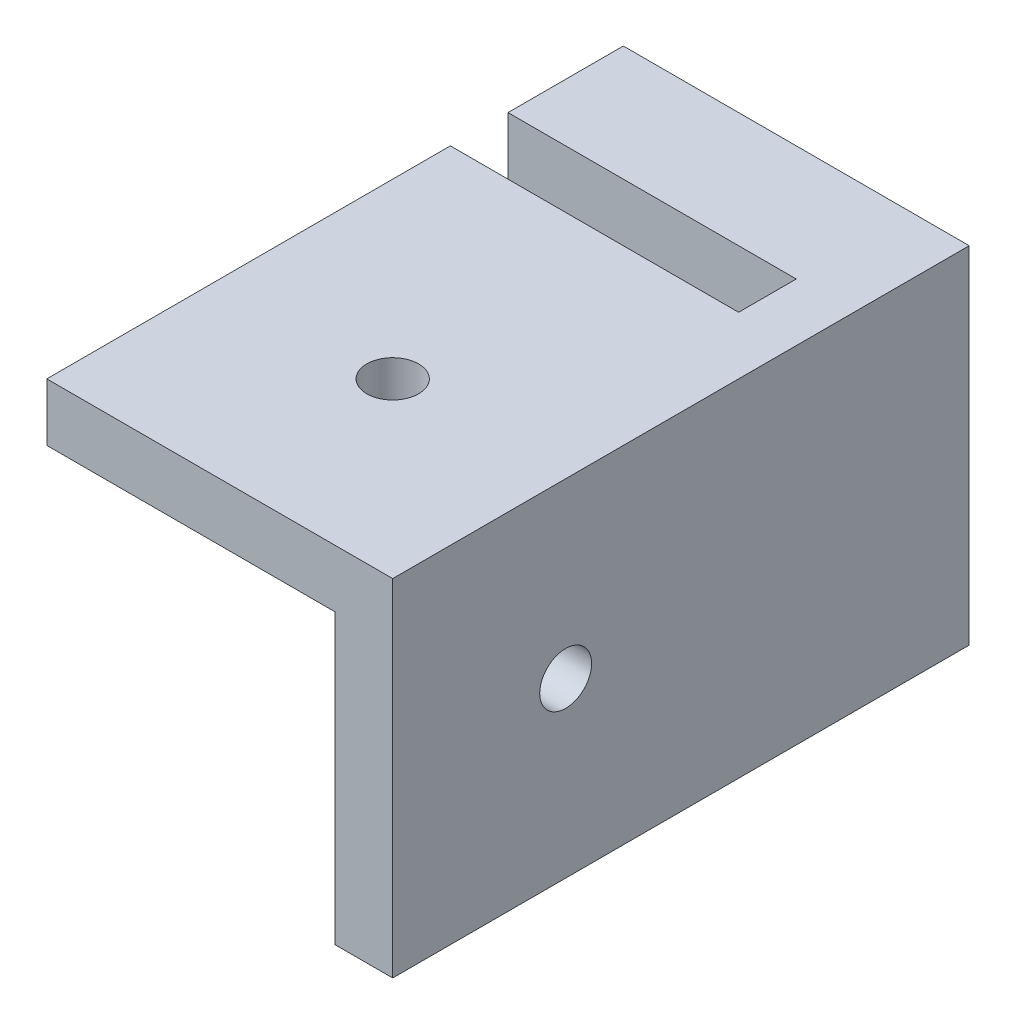
from build123d import *

# Parameters (mm, degrees)
ESBO_O1_W                         = 30
ESBO_O1_H                         = 30
RESSALTO_EXTRUS_O1_DEPTH          = 50
ESBO_O2_W                         = 25
ESBO_O2_H                         = 5
CORTE_EXTRUS_O1_DEPTH             = 31
CORTE_EXTRUS_O2_START             = -5
ESBO_O3_W                         = 25
ESBO_O3_H                         = 25
CORTE_EXTRUS_O2_DEPTH             = 26
FURO_COM_FOLGA_DE_M41_D           = 4.5
FURO_COM_FOLGA_DE_M41_ON_FACE_2_D = 4.5


with BuildPart() as part:
    # Esboço1 → Ressalto-extrusão1 (new body)
    with BuildSketch(Plane.XY):
        with Locations((-15, 15)):
            Rectangle(ESBO_O1_W, ESBO_O1_H)
    extrude(amount=RESSALTO_EXTRUS_O1_DEPTH)

    # Esboço2 → Corte-extrusão1 (cut, through all)
    with BuildSketch(Plane(origin=(0, 30, 0), x_dir=(1, 0, 0), z_dir=(0, 1, 0))):
        with Locations((-17.5, -12.5)):
            Rectangle(ESBO_O2_W, ESBO_O2_H)
    extrude(amount=-CORTE_EXTRUS_O1_DEPTH, mode=Mode.SUBTRACT)

    # Esboço3 → Corte-extrusão2 (cut, through all)
    with BuildSketch(Plane(origin=(0, 30, 0), x_dir=(1, 0, 0), z_dir=(0, 1, 0)).offset(CORTE_EXTRUS_O2_START)):
        with Locations((-17.5, -37.5)):
            Rectangle(ESBO_O3_W, ESBO_O3_H)
    extrude(amount=-CORTE_EXTRUS_O2_DEPTH, mode=Mode.SUBTRACT)

    # Furo com folga de M41 (through all)
    with Locations(Plane(origin=(-5, 15, 35), x_dir=(0, 0, -1), z_dir=(-1, 0, 0))):
        with Locations((0, 0)):
            Hole(FURO_COM_FOLGA_DE_M41_D / 2)

    # Furo com folga de M41 on face 2 (through all)
    with Locations(Plane(origin=(-15, 25, 35), x_dir=(0, 0, -1), z_dir=(0, -1, 0))):
        with Locations((0, 0)):
            Hole(FURO_COM_FOLGA_DE_M41_ON_FACE_2_D / 2)


solid = part.part
